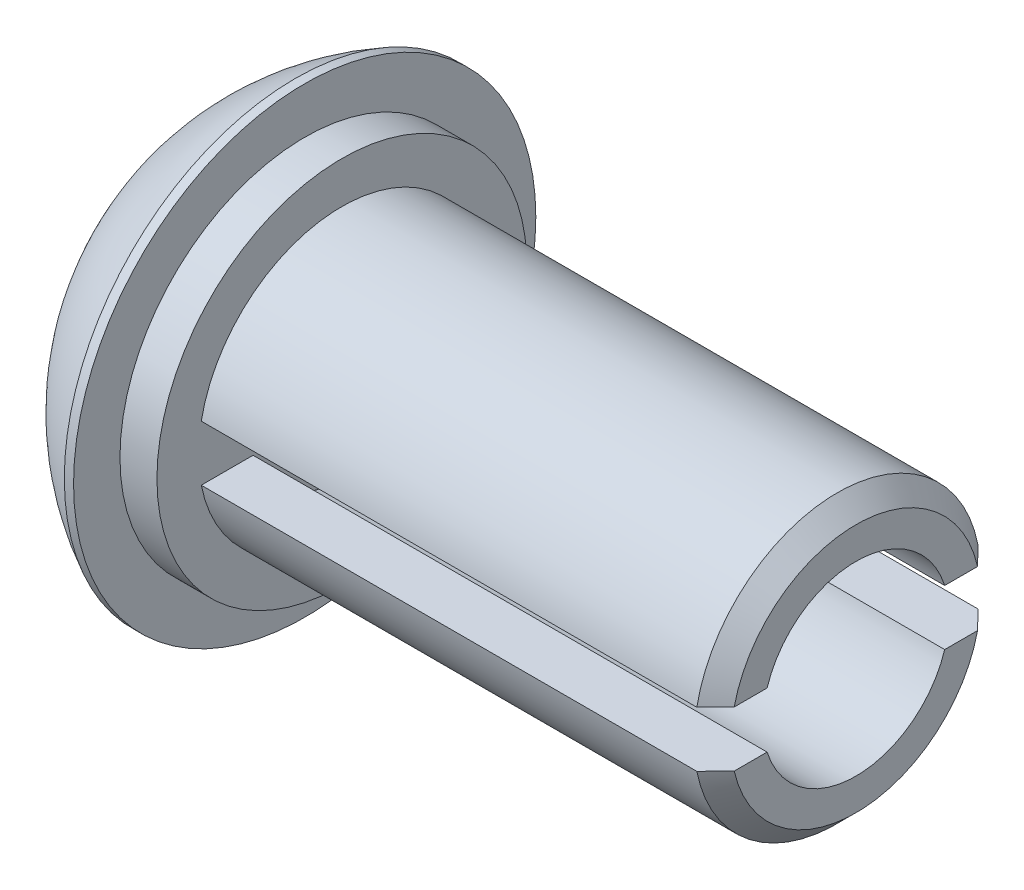
from build123d import *

# Parameters (mm, degrees)
CHAMFER1_SIZE           = 0.254
SKETCH2_W               = 7.0612
SKETCH2_H               = 0.762
CUT_EXTRUDE1_DEPTH      = 4.175
CUT_EXTRUDE1_DEPTH_BACK = 4.175


with BuildPart() as part:
    # Sketch1 → Revolve1 (revolve)
    with BuildSketch(Plane.XY, mode=Mode.PRIVATE) as revolve1_sk:
        with BuildLine():
            Line((1.9558, 3.175), (2.0828, 3.175))
            Line((2.0828, 3.175), (2.0828, 0.889))
            Line((2.0828, 0.889), (2.08534, 0.889))
            Line((2.08534, 0.889), (2.08534, 2.54))
            Line((2.08534, 2.54), (2.59334, 2.54))
            Line((2.59334, 2.54), (2.59334, 1.9685))
            Line((2.59334, 1.9685), (9.65454, 1.9685))
            Line((9.65454, 1.9685), (9.65454, 1.277822692))
            Line((9.65454, 1.277822692), (2.59334, 1.277822692))
            Line((2.59334, 1.277822692), (2.59334, 0))
            Line((2.59334, 0), (0, 0))
            ThreePointArc((0, 0), (0.528187929, 1.864522636), (1.9558, 3.175))
        make_face()
    revolve(revolve1_sk.sketch.rotate(Axis((0, 0, 0), (1, 0, 0)), 90), axis=Axis((0, 0, 0), (1, 0, 0)))  # turned: the seam where the file's is

    # Chamfer1
    chamfer1_edges = [part.edges().sort_by_distance(p)[0] for p in [
        (9.65454, 0, -1.9685),
    ]]
    chamfer(chamfer1_edges, length=CHAMFER1_SIZE)

    # Sketch2 → Cut-Extrude1 (cut, two sides)
    with BuildSketch(Plane.XY) as cut_extrude1_sk:
        with Locations((6.12394, 0)):
            Rectangle(SKETCH2_W, SKETCH2_H)
    extrude(amount=CUT_EXTRUDE1_DEPTH, mode=Mode.SUBTRACT)
    extrude(cut_extrude1_sk.sketch, amount=-CUT_EXTRUDE1_DEPTH_BACK, mode=Mode.SUBTRACT)


solid = part.part
